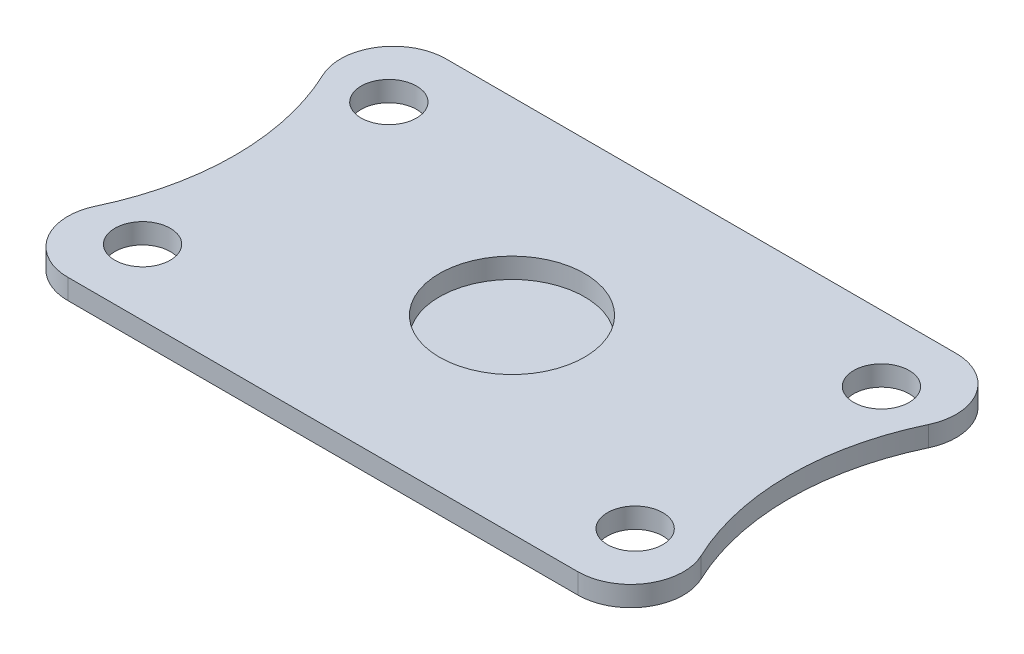
from build123d import *

# Parameters (mm, degrees)
SKETCH_2_R      = 3.15
SKETCH_2_R_2    = 8.25
EXTRUDE_1_DEPTH = 2.3


with BuildPart() as part:
    # ｽｹｯﾁ2 → ﾎﾞｽ - 押し出し1 (new body)
    with BuildSketch(Plane(origin=(0, 0, 0), x_dir=(1, 0, 0), z_dir=(0, 1, 0))):
        with BuildLine():
            Line((-29, 21.5), (29, 21.5))
            ThreePointArc((29, 21.5), (34.072933408, 18.703957965), (34.417821799, 12.921782213))
            ThreePointArc((34.417821799, 12.921782213), (31.500000042, 0), (34.417821799, -12.921782213))
            ThreePointArc((34.417821799, -12.921782213), (34.072933408, -18.703957965), (29, -21.5))
            Line((29, -21.5), (-29, -21.5))
            ThreePointArc((-29, -21.5), (-34.072933408, -18.703957965), (-34.417821799, -12.921782213))
            ThreePointArc((-34.417821799, -12.921782213), (-31.499999945, 0), (-34.417821799, 12.921782213))
            ThreePointArc((-34.417821799, 12.921782213), (-34.072933408, 18.703957965), (-29, 21.5))
        make_face()
        with Locations(Location((28, 14, 0), (0, 0, 270))):
            Circle(SKETCH_2_R, mode=Mode.SUBTRACT)
        with Locations(Location((28, -14, 0), (0, 0, 270))):
            Circle(SKETCH_2_R, mode=Mode.SUBTRACT)
        with Locations(Location((-28, 14, 0), (0, 0, 270))):
            Circle(SKETCH_2_R, mode=Mode.SUBTRACT)
        with Locations(Location((-28, -14, 0), (0, 0, 270))):
            Circle(SKETCH_2_R, mode=Mode.SUBTRACT)
        with Locations(Location((0, 0, 0), (0, 0, 270))):
            Circle(SKETCH_2_R_2, mode=Mode.SUBTRACT)
    extrude(amount=EXTRUDE_1_DEPTH)

    # ｽｹｯﾁ4 → 回転1 (revolve)
    with BuildSketch(Plane.XY, mode=Mode.PRIVATE) as revolve_1_sk:
        with BuildLine():
            Line((13, 0), (0, 0))
            Line((0, 0), (0, -4))
            Line((0, -4), (16, -4))
            Line((16, -4), (16, -3))
            ThreePointArc((16, -3), (15.121320344, -0.878679656), (13, 0))
        make_face()
    revolve(revolve_1_sk.sketch.rotate(Axis((0, 0, 0), (0, -1, 0)), 180), axis=Axis((0, 0, 0), (0, -1, 0)))


solid = part.part
